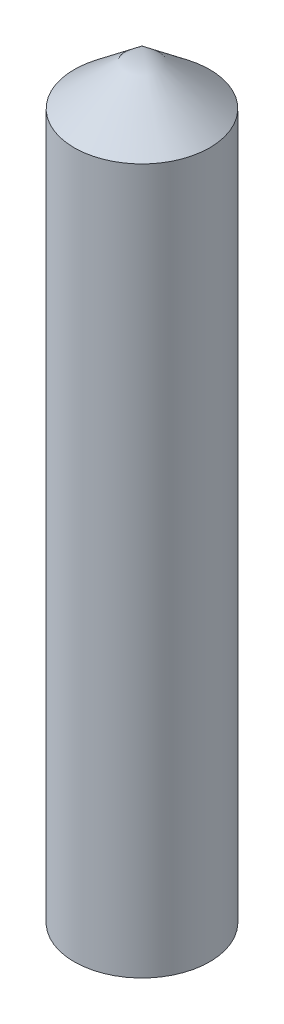
from build123d import *

# Parameters (mm, degrees)
ESQUISSE1_R        = 12.5
BOSS_EXTRU_1_DEPTH = 130


with BuildPart() as part:
    # Esquisse1 → Boss.-Extru.1 (new body)
    with BuildSketch(Plane(origin=(0, 0, 0), x_dir=(1, 0, 0), z_dir=(0, 1, 0))):
        Circle(ESQUISSE1_R)
    extrude(amount=BOSS_EXTRU_1_DEPTH)

    # Esquisse2 → Révolution1 (revolve)
    with BuildSketch(Plane.XY):
        Polygon((-12.5, 130), (0, 140), (0, 130), align=None)
    revolve(axis=Axis((0, 140, 0), (0, -1, 0)))


solid = part.part
